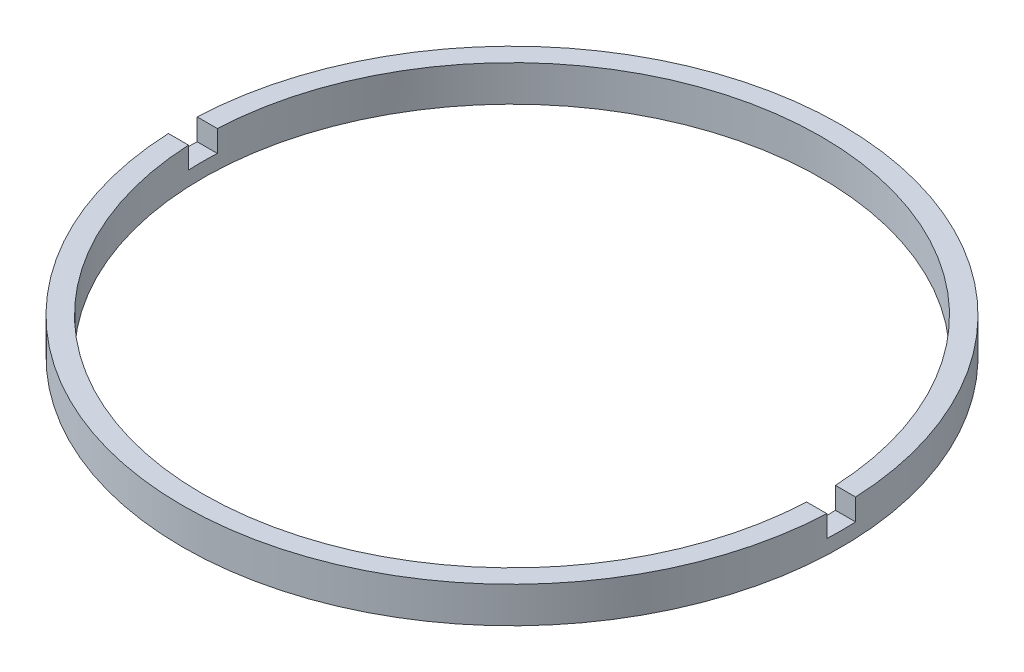
from build123d import *

# Parameters (mm, degrees)
SKETCH_1_W          = 1.4
SKETCH_1_H          = 2.5
SKETCH_2_W          = 53.705080546
SKETCH_2_H          = 2
CUT_EXTRUDE_1_DEPTH = 1.5


with BuildPart() as part:
    # 草图1 → 旋转1 (revolve)
    with BuildSketch(Plane.XY, mode=Mode.PRIVATE) as revolve_1_sk:
        with Locations((22.2, -3.214249787)):
            Rectangle(SKETCH_1_W, SKETCH_1_H)
    revolve(revolve_1_sk.sketch.rotate(Axis((0, 56.260842627, 0), (0, -1, 0)), 90), axis=Axis((0, 56.260842627, 0), (0, -1, 0)))  # turned: the seam where the file's is

    # 草图2 → 切除-拉伸1 (cut)
    with BuildSketch(Plane(origin=(0, -1.964249787, 0), x_dir=(1, 0, 0), z_dir=(0, 1, 0))):
        Rectangle(SKETCH_2_W, SKETCH_2_H)
    extrude(amount=-CUT_EXTRUDE_1_DEPTH, mode=Mode.SUBTRACT)


solid = part.part
